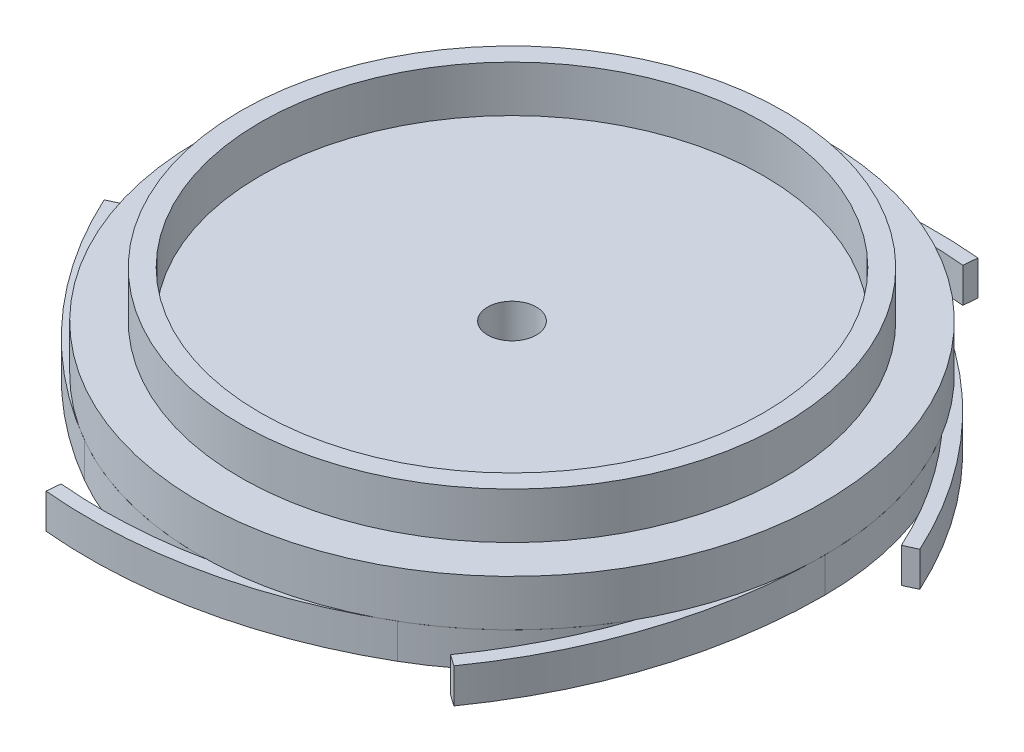
from build123d import *

# Parameters (mm, degrees)
BOSS_EXTRUDE1_DEPTH = 3
SKETCH23_W          = 2.1
SKETCH23_H          = 7
CUT_EXTRUDE1_DEPTH  = 4


with BuildPart() as part:
    # Sketch1 → Revolve1 (revolve)
    with BuildSketch(Plane.XY):
        Polygon((-23.425, 0), (-23.425, -4), (-27, -4), (-27, -8), (0, -8), (0, -4), (-21.721500416, -4), (-21.721500416, 0), align=None)
    revolve(axis=Axis((0, -8, 0), (0, -1, 0)))


with BuildPart() as body_2:
    # Sketch18 → Boss-Extrude1 (new body)
    with BuildSketch(Plane.XZ.offset(8)):
        with BuildLine():
            Line((18.287619048, 23.591829478), (19.266666667, 24.285706816))
            ThreePointArc((19.266666667, 24.285706816), (25.019995002, 12.743625858), (27, 0))
            ThreePointArc((27, 0), (25.997622732, -7.288594671), (23.06491761, -14.036009962))
            ThreePointArc((23.06491761, -14.036009962), (26.687121428, -9.277998508), (29.574933174, -4.041627931))
            Line((29.574933174, -4.041627931), (30.665372385, -4.542569372))
            ThreePointArc((30.665372385, -4.542569372), (23.54630123, -15.296138346), (13.5, -23.382685902))
            ThreePointArc((13.5, -23.382685902), (6.686703224, -26.158899059), (-0.62308239, -26.992809567))
            ThreePointArc((-0.62308239, -26.992809567), (5.30857831, -27.750724365), (11.287314126, -27.633457409))
            Line((11.287314126, -27.633457409), (11.398705718, -28.828276188))
            ThreePointArc((11.398705718, -28.828276188), (-1.473693772, -28.039764204), (-13.5, -23.382685902))
            ThreePointArc((-13.5, -23.382685902), (-19.310919509, -18.870304389), (-23.688, -12.956799605))
            ThreePointArc((-23.688, -12.956799605), (-21.378543119, -18.472725857), (-18.287619048, -23.591829478))
            Line((-18.287619048, -23.591829478), (-19.266666667, -24.285706816))
            ThreePointArc((-19.266666667, -24.285706816), (-25.019995002, -12.743625858), (-27, 0))
            ThreePointArc((-27, 0), (-25.997622732, 7.288594671), (-23.06491761, 14.036009962))
            ThreePointArc((-23.06491761, 14.036009962), (-26.687121428, 9.277998508), (-29.574933174, 4.041627931))
            Line((-29.574933174, 4.041627931), (-30.665372385, 4.542569372))
            ThreePointArc((-30.665372385, 4.542569372), (-23.54630123, 15.296138346), (-13.5, 23.382685902))
            ThreePointArc((-13.5, 23.382685902), (-6.686703224, 26.158899059), (0.62308239, 26.992809567))
            ThreePointArc((0.62308239, 26.992809567), (-5.30857831, 27.750724365), (-11.287314126, 27.633457409))
            Line((-11.287314126, 27.633457409), (-11.398705718, 28.828276188))
            ThreePointArc((-11.398705718, 28.828276188), (1.473693772, 28.039764204), (13.5, 23.382685902))
            ThreePointArc((13.5, 23.382685902), (19.310919509, 18.870304389), (23.688, 12.956799605))
            ThreePointArc((23.688, 12.956799605), (21.378543119, 18.472725857), (18.287619048, 23.591829478))
        make_face()
    extrude(amount=BOSS_EXTRUDE1_DEPTH)


with BuildPart() as f_4_2_4_2_diameter_hole1_tool:
    # Sketch23 → Ø4.2 (4.2) Diameter Hole1 (revolve)
    with BuildSketch(Plane(origin=(0, -4, 0), x_dir=(0, 0, 1), z_dir=(1, 0, 0))):
        with Locations((1.05, 3.5)):
            Rectangle(SKETCH23_W, SKETCH23_H)
    revolve(axis=Axis((0, 2.35, 0), (0, -1, 0)))


with BuildPart() as part_1:
    add(part.part)

    # Ø4.2 (4.2) Diameter Hole1: cut by f_4_2_4_2_diameter_hole1_tool
    add(f_4_2_4_2_diameter_hole1_tool.part, mode=Mode.SUBTRACT)


with BuildPart() as body_2_1:
    add(body_2.part)

    # Ø4.2 (4.2) Diameter Hole1: cut by f_4_2_4_2_diameter_hole1_tool
    add(f_4_2_4_2_diameter_hole1_tool.part, mode=Mode.SUBTRACT)


with BuildPart() as cut_extrude1_tool:
    # Sketch19 → Cut-Extrude1 (new body)
    with BuildSketch(Plane.XZ.offset(11)):
        Polygon((0, -4.156921938), (3.6, -2.078460969), (3.6, 2.078460969), (0, 4.156921938), (-3.6, 2.078460969), (-3.6, -2.078460969), align=None)
    extrude(amount=-CUT_EXTRUDE1_DEPTH)


with BuildPart() as part_2:
    add(part_1.part)

    # Cut-Extrude1: cut by cut_extrude1_tool
    add(cut_extrude1_tool.part, mode=Mode.SUBTRACT)


with BuildPart() as body_2_2:
    add(body_2_1.part)

    # Cut-Extrude1: cut by cut_extrude1_tool
    add(cut_extrude1_tool.part, mode=Mode.SUBTRACT)


solid = Compound([part_2.part, body_2_2.part])
